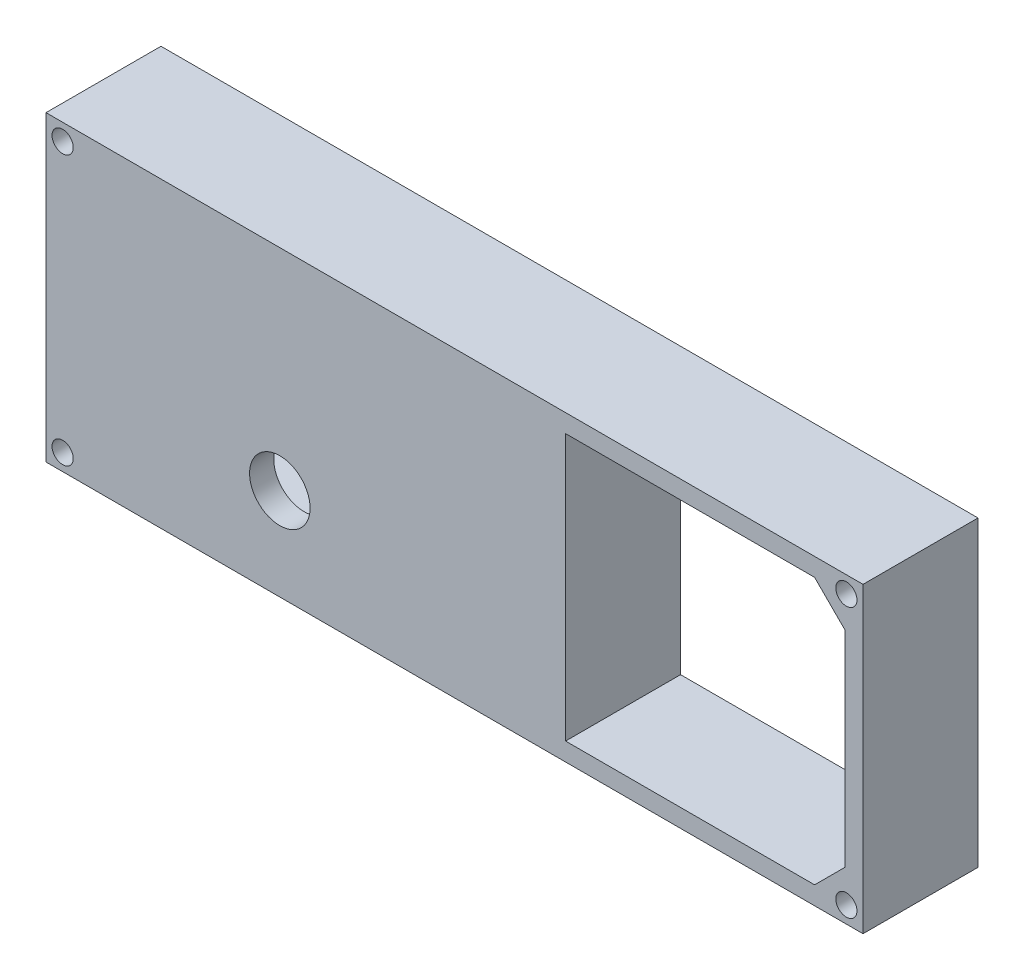
from build123d import *

# Parameters (mm, degrees)
CROQUIS1_W              = 135
CROQUIS1_H              = 50
CROQUIS1_R              = 0.85
SALIENTE_EXTRUIR1_DEPTH = 15
CROQUIS2_W              = 135
CROQUIS2_H              = 50
CROQUIS2_R              = 0.85
CROQUIS2_R_2            = 5
SALIENTE_EXTRUIR2_DEPTH = 4
CROQUIS3_R              = 1.75
CORTAR_EXTRUIR1_DEPTH   = 12


with BuildPart() as part:
    # Croquis1 → Saliente-Extruir1 (new body)
    with BuildSketch(Plane.XY):
        with Locations((-0.262377426, 0.111379231)):
            Rectangle(CROQUIS1_W, CROQUIS1_H)
        with Locations((-65.012377426, 22.361379231)):
            Circle(CROQUIS1_R, mode=Mode.SUBTRACT)
        with Locations((-65.012377426, -22.138620769)):
            Circle(CROQUIS1_R, mode=Mode.SUBTRACT)
        with Locations((64.487622574, -22.138620769)):
            Circle(CROQUIS1_R, mode=Mode.SUBTRACT)
        with Locations((64.487622574, 22.361379231)):
            Circle(CROQUIS1_R, mode=Mode.SUBTRACT)
        Polygon((-64.762377426, 17.111379231), (-64.762377426, -16.888620769), (-59.762377426, -21.888620769), (15.089266591, -21.888620769), (15.089266591, 22.111379231), (-59.762377426, 22.111379231), align=None, mode=Mode.SUBTRACT)
        Polygon((64.237622574, 17.111379231), (59.237622574, 22.111379231), (18.089266591, 22.111379231), (18.089266591, -21.888620769), (59.237622574, -21.888620769), (64.237622574, -16.888620769), align=None, mode=Mode.SUBTRACT)
    extrude(amount=SALIENTE_EXTRUIR1_DEPTH)

    # Croquis2 → Saliente-Extruir2 (add)
    with BuildSketch(Plane.XY.offset(15)):
        with Locations((-0.262377426, 0.111379231)):
            Rectangle(CROQUIS2_W, CROQUIS2_H)
        with Locations((-65.012377426, 22.361379231)):
            Circle(CROQUIS2_R, mode=Mode.SUBTRACT)
        with Locations((64.487622574, 22.361379231)):
            Circle(CROQUIS2_R, mode=Mode.SUBTRACT)
        with Locations((64.487622574, -22.138620769)):
            Circle(CROQUIS2_R, mode=Mode.SUBTRACT)
        with Locations((-65.012377426, -22.138620769)):
            Circle(CROQUIS2_R, mode=Mode.SUBTRACT)
        with Locations((-29.126949829, -9.66737546)):
            Circle(CROQUIS2_R_2, mode=Mode.SUBTRACT)
        Polygon((18.089266591, 22.111379231), (18.089266591, -21.888620769), (59.237622574, -21.888620769), (64.237622574, -16.888620769), (64.237622574, 17.111379231), (59.237622574, 22.111379231), align=None, mode=Mode.SUBTRACT)
    extrude(amount=SALIENTE_EXTRUIR2_DEPTH)

    # Croquis3 → Cortar-Extruir1 (cut)
    with BuildSketch(Plane.XY.offset(19)):
        with Locations((64.487622574, 22.361379231)):
            Circle(CROQUIS3_R)
        with Locations((64.487622574, -22.138620769)):
            Circle(CROQUIS3_R)
        with Locations((-65.012377426, -22.138620769)):
            Circle(CROQUIS3_R)
        with Locations((-65.012377426, 22.361379231)):
            Circle(CROQUIS3_R)
    extrude(amount=-CORTAR_EXTRUIR1_DEPTH, mode=Mode.SUBTRACT)


solid = part.part
